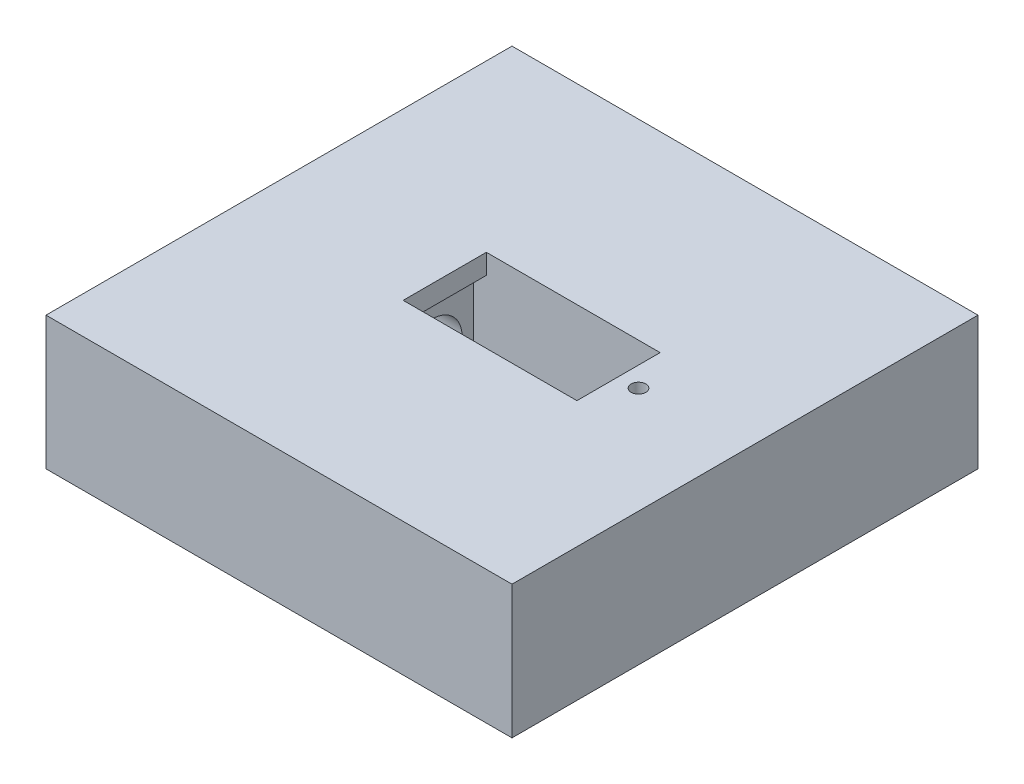
from build123d import *

# Parameters (mm, degrees)
CROQUIS1_W              = 64
CROQUIS1_H              = 64
SALIENTE_EXTRUIR1_DEPTH = 60
CROQUIS2_W              = 70
CROQUIS2_H              = 70
CROQUIS2_W_2            = 64
CROQUIS2_H_2            = 64
SALIENTE_EXTRUIR2_DEPTH = 64
CORTAR_EXTRUIR1_DEPTH   = 21
CROQUIS5_R              = 1.1
CORTAR_EXTRUIR2_DEPTH   = 10
CORTAR_EXTRUIR3_REACH   = 30
CROQUIS10_R             = 4.5
CROQUIS11_W             = 70
CROQUIS11_H             = 70
CORTAR_EXTRUIR4_DEPTH   = 30
CROQUIS12_W             = 23
CROQUIS12_H             = 12.2
CORTAR_EXTRUIR5_DEPTH   = 21
CORTAR_EXTRUIR6_REACH   = 30
CROQUIS13_R             = 4.5
CROQUIS14_R             = 1.1
CORTAR_EXTRUIR7_DEPTH   = 10
CROQUIS15_R             = 3.7
CORTAR_EXTRUIR8_DEPTH   = 10
CROQUIS16_W             = 64
CROQUIS16_H             = 64
CORTAR_EXTRUIR9_DEPTH   = 5
CROQUIS17_W             = 12.5
CROQUIS17_H             = 12.998685397
CORTAR_EXTRUIR10_DEPTH  = 5
CORTAR_EXTRUIR11_REACH  = 72
CROQUIS18_W             = 70
CROQUIS18_H             = 9
CROQUIS18_H_2           = 5.000169364
CORTAR_EXTRUIR13_DEPTH  = 5
CORTAR_EXTRUIR16_REACH  = 5.001
CROQUIS23_W             = 3.1
CROQUIS23_H             = 12.5
CORTAR_EXTRUIR17_REACH  = 5
CROQUIS22_W             = 3.1
CROQUIS22_H             = 12.2


with BuildPart() as part:
    # Croquis1 → Saliente-Extruir1 (new body)
    with BuildSketch(Plane(origin=(0, 0, 0), x_dir=(1, 0, 0), z_dir=(0, 1, 0))):
        Rectangle(CROQUIS1_W, CROQUIS1_H)
    extrude(amount=SALIENTE_EXTRUIR1_DEPTH)

    # Croquis2 → Saliente-Extruir2 (add)
    with BuildSketch(Plane(origin=(0, 0, 0), x_dir=(1, 0, 0), z_dir=(0, 1, 0))):
        Rectangle(CROQUIS2_W, CROQUIS2_H)
        Rectangle(CROQUIS2_W_2, CROQUIS2_H_2, mode=Mode.SUBTRACT)
    extrude(amount=SALIENTE_EXTRUIR2_DEPTH)

    # Croquis4 → Cortar-Extruir1 (cut)
    with BuildSketch(Plane(origin=(0, 60, 0), x_dir=(1, 0, 0), z_dir=(0, 1, 0))):
        Polygon((-7, 6), (-7, -6), (-7, -6.25), (16, -6.25), (16, -6), (16, 6), (16, 6.25), (-7, 6.25), align=None)
    extrude(amount=-CORTAR_EXTRUIR1_DEPTH, mode=Mode.SUBTRACT)

    # Croquis5 → Cortar-Extruir2 (cut)
    with BuildSketch(Plane(origin=(0, 60, 0), x_dir=(1, 0, 0), z_dir=(0, 1, 0))):
        with Locations((19, 0)):
            Circle(CROQUIS5_R)
        with Locations((-9, 0)):
            Circle(CROQUIS5_R)
    extrude(amount=-CORTAR_EXTRUIR2_DEPTH, mode=Mode.SUBTRACT)

    # Croquis10 → Cortar-Extruir3 (cut, up to next)
    with BuildSketch(Plane(origin=(-7, 0, 0), x_dir=(0, 0, -1), z_dir=(1, 0, 0)), mode=Mode.PRIVATE) as cortar_extruir3_sk1:
        with Locations((0, 44)):
            Circle(CROQUIS10_R)
    cortar_extruir3_tool1 = extrude(cortar_extruir3_sk1.sketch, amount=-CORTAR_EXTRUIR3_REACH, mode=Mode.PRIVATE) & part.part
    add(cortar_extruir3_tool1.solids().sort_by_distance((-7, 44, 0))[0], mode=Mode.SUBTRACT)

    # Croquis11 → Cortar-Extruir4 (cut)
    with BuildSketch(Plane.XZ):
        Rectangle(CROQUIS11_W, CROQUIS11_H)
    extrude(amount=-CORTAR_EXTRUIR4_DEPTH, mode=Mode.SUBTRACT)

    # Croquis12 → Cortar-Extruir5 (cut)
    with BuildSketch(Plane.XZ.offset(-30)):
        with Locations((4.5, 22.1)):
            Rectangle(CROQUIS12_W, CROQUIS12_H)
    extrude(amount=-CORTAR_EXTRUIR5_DEPTH, mode=Mode.SUBTRACT)

    # Croquis13 → Cortar-Extruir6 (cut, up to next)
    with BuildSketch(Plane(origin=(-7, 0, 0), x_dir=(0, 0, -1), z_dir=(1, 0, 0)), mode=Mode.PRIVATE) as cortar_extruir6_sk1:
        with Locations((-22.1, 46)):
            Circle(CROQUIS13_R)
    cortar_extruir6_tool1 = extrude(cortar_extruir6_sk1.sketch, amount=-CORTAR_EXTRUIR6_REACH, mode=Mode.PRIVATE) & part.part
    add(cortar_extruir6_tool1.solids().sort_by_distance((-7, 46, 22.1))[0], mode=Mode.SUBTRACT)

    # Croquis14 → Cortar-Extruir7 (cut)
    with BuildSketch(Plane.XZ.offset(-30)):
        with Locations((19, 22.1)):
            Circle(CROQUIS14_R)
        with Locations((-9, 22.1)):
            Circle(CROQUIS14_R)
    extrude(amount=-CORTAR_EXTRUIR7_DEPTH, mode=Mode.SUBTRACT)

    # Croquis15 → Cortar-Extruir8 (cut)
    with BuildSketch(Plane.XZ.offset(-30)):
        with Locations((0, -22.1)):
            Circle(CROQUIS15_R)
    extrude(amount=-CORTAR_EXTRUIR8_DEPTH, mode=Mode.SUBTRACT)

    # Croquis16 → Cortar-Extruir9 (cut)
    with BuildSketch(Plane(origin=(0, 60, 0), x_dir=(1, 0, 0), z_dir=(0, 1, 0))):
        Rectangle(CROQUIS16_W, CROQUIS16_H)
    extrude(amount=-CORTAR_EXTRUIR9_DEPTH, mode=Mode.SUBTRACT)

    # Croquis17 → Cortar-Extruir10 (cut)
    with BuildSketch(Plane(origin=(-7, 0, 0), x_dir=(0, 0, -1), z_dir=(1, 0, 0))):
        with Locations((0, 45.499342699)):
            Rectangle(CROQUIS17_W, CROQUIS17_H)
    extrude(amount=-CORTAR_EXTRUIR10_DEPTH, mode=Mode.SUBTRACT)

    # Croquis18 → Cortar-Extruir11 (cut, up to next)
    with BuildSketch(Plane(origin=(35, 0, 0), x_dir=(0, 0, -1), z_dir=(1, 0, 0)), mode=Mode.PRIVATE) as cortar_extruir11_sk1:
        with Locations((0, 59.5)):
            Rectangle(CROQUIS18_W, CROQUIS18_H)
    cortar_extruir11_tool1 = extrude(cortar_extruir11_sk1.sketch, amount=-CORTAR_EXTRUIR11_REACH, mode=Mode.PRIVATE) & part.part
    add(cortar_extruir11_tool1.solids().sort_by_distance((35, 59.5, 0))[0], mode=Mode.SUBTRACT)
    # Croquis18 → Cortar-Extruir11 (cut, up to next)
    with BuildSketch(Plane(origin=(35, 0, 0), x_dir=(0, 0, -1), z_dir=(1, 0, 0)), mode=Mode.PRIVATE) as cortar_extruir11_sk2:
        with Locations((0, 32.500084682)):
            Rectangle(CROQUIS18_W, CROQUIS18_H_2)
    cortar_extruir11_tool2 = extrude(cortar_extruir11_sk2.sketch, amount=-CORTAR_EXTRUIR11_REACH, mode=Mode.PRIVATE) & part.part
    add(cortar_extruir11_tool2.solids().sort_by_distance((35, 32.500085, 0))[0], mode=Mode.SUBTRACT)

    # Croquis19 → Cortar-Extruir13 (cut)
    with BuildSketch(Plane(origin=(-7, 0, 0), x_dir=(0, 0, -1), z_dir=(1, 0, 0))):
        Polygon((-16, 51), (-28.2, 51), (-28.2, 38.000169364), (-22.1, 38.000169364), (-16, 38.000169364), align=None)
    extrude(amount=-CORTAR_EXTRUIR13_DEPTH, mode=Mode.SUBTRACT)

    # Croquis23 → Cortar-Extruir16 (cut, up to next)
    with BuildSketch(Plane.XZ.offset(-51.998685397), mode=Mode.PRIVATE) as cortar_extruir16_sk1:
        with Locations((-8.55, 0)):
            Rectangle(CROQUIS23_W, CROQUIS23_H)
    cortar_extruir16_tool1 = extrude(cortar_extruir16_sk1.sketch, amount=-CORTAR_EXTRUIR16_REACH, mode=Mode.PRIVATE) & part.part
    add(cortar_extruir16_tool1.solids().sort_by_distance((-8.55, 51.998685, 0))[0], mode=Mode.SUBTRACT)

    # Croquis22 → Cortar-Extruir17 (cut, up to next)
    with BuildSketch(Plane(origin=(0, 38.000169364, 0), x_dir=(1, 0, 0), z_dir=(0, 1, 0)), mode=Mode.PRIVATE) as cortar_extruir17_sk1:
        with Locations((-8.55, -22.1)):
            Rectangle(CROQUIS22_W, CROQUIS22_H)
    cortar_extruir17_tool1 = extrude(cortar_extruir17_sk1.sketch, amount=-CORTAR_EXTRUIR17_REACH, mode=Mode.PRIVATE) & part.part
    add(cortar_extruir17_tool1.solids().sort_by_distance((-8.55, 38.000169, 22.1))[0], mode=Mode.SUBTRACT)


solid = part.part
